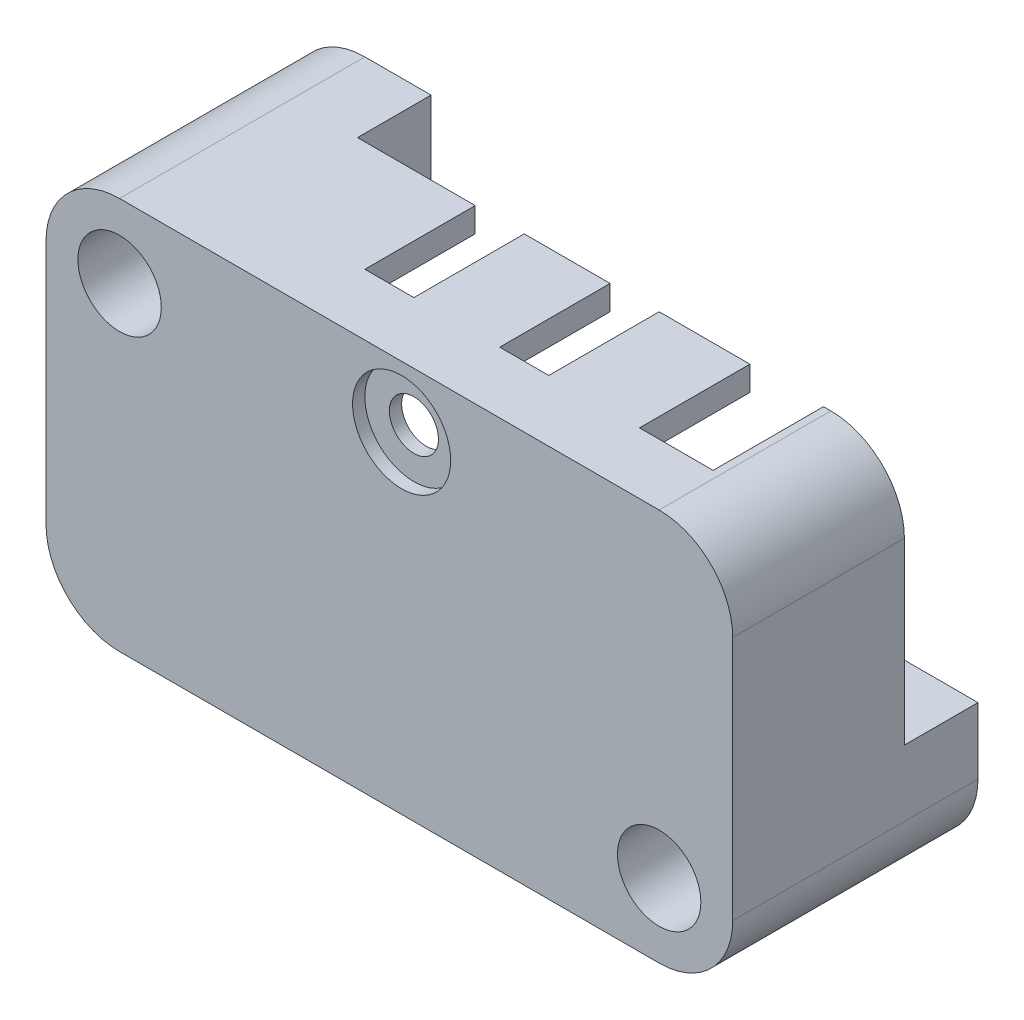
from build123d import *

# Parameters (mm, degrees)
SZKIC1_W                        = 28
SZKIC1_H                        = 16
DODANIE_WYCI_GNI_CIE1_DEPTH     = 10
WYTNIJ_WYCI_GNI_CIE1_REACH      = 12
SZKIC2_R                        = 1.7
ZAOKR_GLENIE1_R                 = 3
WYTNIJ_WYCI_GNI_CIE2_DEPTH      = 4
WYTNIJ_WYCI_GNI_CIE2_DEPTH_BACK = 4
WYTNIJ_WYCI_GNI_CIE3_DEPTH      = 3
WYTNIJ_WYCI_GNI_CIE4_REACH      = 18
SZKIC5_W                        = 2
SZKIC5_H                        = 4.5
SZKIC5_W_2                      = 3
SZKIC6_R                        = 2
WYTNIJ_WYCI_GNI_CIE5_DEPTH      = 0.5
WYTNIJ_WYCI_GNI_CIE6_REACH      = 11.5
SZKIC7_R                        = 1
WYTNIJ_WYCI_GNI_CIE7_REACH      = 30
SZKIC8_W                        = 5
SZKIC8_H                        = 1
WYTNIJ_WYCI_GNI_CIE8_REACH      = 18
SZKIC9_W                        = 1
SZKIC9_H                        = 5


with BuildPart() as part:
    # Szkic1 → Dodanie-wyciągnięcie1 (new body)
    with BuildSketch(Plane.XY):
        Rectangle(SZKIC1_W, SZKIC1_H)
    extrude(amount=DODANIE_WYCI_GNI_CIE1_DEPTH)

    # Szkic2 → Wytnij-wyciągnięcie1 (cut, up to next)
    with BuildSketch(Plane.XY.offset(10), mode=Mode.PRIVATE) as wytnij_wyci_gni_cie1_sk1:
        with Locations((-11, 5)):
            Circle(SZKIC2_R)
    wytnij_wyci_gni_cie1_tool1 = extrude(wytnij_wyci_gni_cie1_sk1.sketch, amount=-WYTNIJ_WYCI_GNI_CIE1_REACH, mode=Mode.PRIVATE) & part.part
    add(wytnij_wyci_gni_cie1_tool1.solids().sort_by_distance((-11, 5, 10))[0], mode=Mode.SUBTRACT)
    # Szkic2 → Wytnij-wyciągnięcie1 (cut, up to next)
    with BuildSketch(Plane.XY.offset(10), mode=Mode.PRIVATE) as wytnij_wyci_gni_cie1_sk2:
        with Locations((11, -5)):
            Circle(SZKIC2_R)
    wytnij_wyci_gni_cie1_tool2 = extrude(wytnij_wyci_gni_cie1_sk2.sketch, amount=-WYTNIJ_WYCI_GNI_CIE1_REACH, mode=Mode.PRIVATE) & part.part
    add(wytnij_wyci_gni_cie1_tool2.solids().sort_by_distance((11, -5, 10))[0], mode=Mode.SUBTRACT)

    # Zaokrąglenie1
    zaokr_glenie1_edges = [part.edges().sort_by_distance(p)[0] for p in [
        (14, -8, 5),
        (-14, -8, 5),
        (-14, 8, 5),
        (14, 8, 5),
    ]]
    fillet(zaokr_glenie1_edges, radius=ZAOKR_GLENIE1_R)

    # Szkic3 → Wytnij-wyciągnięcie2 (cut, two sides)
    with BuildSketch(Plane.XY.offset(5)) as wytnij_wyci_gni_cie2_sk:
        with BuildLine():
            Line((11, 7), (-7.3, 7))
            ThreePointArc((-7.3, 7), (-8.007106781, 6.707106781), (-8.3, 6))
            Line((-8.3, 6), (-8.3, 5))
            ThreePointArc((-8.3, 5), (-9.090811691, 3.090811691), (-11, 2.3))
            Line((-11, 2.3), (-12, 2.3))
            ThreePointArc((-12, 2.3), (-12.707106781, 2.007106781), (-13, 1.3))
            Line((-13, 1.3), (-13, -5))
            ThreePointArc((-13, -5), (-12.414213562, -6.414213562), (-11, -7))
            Line((-11, -7), (7.3, -7))
            ThreePointArc((7.3, -7), (8.007106781, -6.707106781), (8.3, -6))
            Line((8.3, -6), (8.3, -5))
            ThreePointArc((8.3, -5), (9.090811691, -3.090811691), (11, -2.3))
            Line((11, -2.3), (12, -2.3))
            ThreePointArc((12, -2.3), (12.707106781, -2.007106781), (13, -1.3))
            Line((13, -1.3), (13, 5))
            ThreePointArc((13, 5), (12.414213562, 6.414213562), (11, 7))
        make_face()
    extrude(amount=WYTNIJ_WYCI_GNI_CIE2_DEPTH, mode=Mode.SUBTRACT)
    extrude(wytnij_wyci_gni_cie2_sk.sketch, amount=-WYTNIJ_WYCI_GNI_CIE2_DEPTH_BACK, mode=Mode.SUBTRACT)

    # Szkic4 → Wytnij-wyciągnięcie3 (cut)
    with BuildSketch(Plane(origin=(0, 0, 0), x_dir=(-1, 0, 0), z_dir=(0, 0, -1))):
        with BuildLine():
            Line((-11, 8), (8.3, 8))
            Line((8.3, 8), (8.3, 5))
            ThreePointArc((8.3, 5), (9.090811691, 3.090811691), (11, 2.3))
            Line((11, 2.3), (14, 2.3))
            Line((14, 2.3), (14, -5))
            ThreePointArc((14, -5), (13.121320344, -7.121320344), (11, -8))
            Line((11, -8), (-8.3, -8))
            Line((-8.3, -8), (-8.3, -5))
            ThreePointArc((-8.3, -5), (-9.090811691, -3.090811691), (-11, -2.3))
            Line((-11, -2.3), (-14, -2.3))
            Line((-14, -2.3), (-14, 5))
            ThreePointArc((-14, 5), (-13.121320344, 7.121320344), (-11, 8))
        make_face()
    extrude(amount=-WYTNIJ_WYCI_GNI_CIE3_DEPTH, mode=Mode.SUBTRACT)

    # Szkic5 → Wytnij-wyciągnięcie4 (cut, up to next)
    with BuildSketch(Plane(origin=(0, 8, 0), x_dir=(1, 0, 0), z_dir=(0, 1, 0)), mode=Mode.PRIVATE) as wytnij_wyci_gni_cie4_sk1:
        with Locations((3, -5.25)):
            Rectangle(SZKIC5_W, SZKIC5_H)
    wytnij_wyci_gni_cie4_tool1 = extrude(wytnij_wyci_gni_cie4_sk1.sketch, amount=-WYTNIJ_WYCI_GNI_CIE4_REACH, mode=Mode.PRIVATE) & part.part
    add(wytnij_wyci_gni_cie4_tool1.solids().sort_by_distance((3, 8, 5.25))[0], mode=Mode.SUBTRACT)
    # Szkic5 → Wytnij-wyciągnięcie4 (cut, up to next)
    with BuildSketch(Plane(origin=(0, 8, 0), x_dir=(1, 0, 0), z_dir=(0, 1, 0)), mode=Mode.PRIVATE) as wytnij_wyci_gni_cie4_sk2:
        with Locations((9.2, -5.25)):
            Rectangle(SZKIC5_W_2, SZKIC5_H)
    wytnij_wyci_gni_cie4_tool2 = extrude(wytnij_wyci_gni_cie4_sk2.sketch, amount=-WYTNIJ_WYCI_GNI_CIE4_REACH, mode=Mode.PRIVATE) & part.part
    add(wytnij_wyci_gni_cie4_tool2.solids().sort_by_distance((9.2, 8, 5.25))[0], mode=Mode.SUBTRACT)
    # Szkic5 → Wytnij-wyciągnięcie4 (cut, up to next)
    with BuildSketch(Plane(origin=(0, 8, 0), x_dir=(1, 0, 0), z_dir=(0, 1, 0)), mode=Mode.PRIVATE) as wytnij_wyci_gni_cie4_sk3:
        with Locations((-2.5, -5.25)):
            Rectangle(SZKIC5_W, SZKIC5_H)
    wytnij_wyci_gni_cie4_tool3 = extrude(wytnij_wyci_gni_cie4_sk3.sketch, amount=-WYTNIJ_WYCI_GNI_CIE4_REACH, mode=Mode.PRIVATE) & part.part
    add(wytnij_wyci_gni_cie4_tool3.solids().sort_by_distance((-2.5, 8, 5.25))[0], mode=Mode.SUBTRACT)

    # Szkic6 → Wytnij-wyciągnięcie5 (cut)
    with BuildSketch(Plane.XY.offset(10)):
        with Locations((0.5, 5.5)):
            Circle(SZKIC6_R)
    extrude(amount=-WYTNIJ_WYCI_GNI_CIE5_DEPTH, mode=Mode.SUBTRACT)

    # Szkic7 → Wytnij-wyciągnięcie6 (cut, up to next)
    with BuildSketch(Plane.XY.offset(9.5), mode=Mode.PRIVATE) as wytnij_wyci_gni_cie6_sk1:
        with Locations((0.5, 5.5)):
            Circle(SZKIC7_R)
    wytnij_wyci_gni_cie6_tool1 = extrude(wytnij_wyci_gni_cie6_sk1.sketch, amount=-WYTNIJ_WYCI_GNI_CIE6_REACH, mode=Mode.PRIVATE) & part.part
    add(wytnij_wyci_gni_cie6_tool1.solids().sort_by_distance((0.5, 5.5, 9.5))[0], mode=Mode.SUBTRACT)

    # Szkic8 → Wytnij-wyciągnięcie7 (cut, up to next)
    with BuildSketch(Plane.ZY.offset(14), mode=Mode.PRIVATE) as wytnij_wyci_gni_cie7_sk1:
        with Locations((5.5, 1.6)):
            Rectangle(SZKIC8_W, SZKIC8_H)
    wytnij_wyci_gni_cie7_tool1 = extrude(wytnij_wyci_gni_cie7_sk1.sketch, amount=-WYTNIJ_WYCI_GNI_CIE7_REACH, mode=Mode.PRIVATE) & part.part
    add(wytnij_wyci_gni_cie7_tool1.solids().sort_by_distance((-14, 1.6, 5.5))[0], mode=Mode.SUBTRACT)
    # Szkic8 → Wytnij-wyciągnięcie7 (cut, up to next)
    with BuildSketch(Plane.ZY.offset(14), mode=Mode.PRIVATE) as wytnij_wyci_gni_cie7_sk2:
        with Locations((5.5, -3.8)):
            Rectangle(SZKIC8_W, SZKIC8_H)
    wytnij_wyci_gni_cie7_tool2 = extrude(wytnij_wyci_gni_cie7_sk2.sketch, amount=-WYTNIJ_WYCI_GNI_CIE7_REACH, mode=Mode.PRIVATE) & part.part
    add(wytnij_wyci_gni_cie7_tool2.solids().sort_by_distance((-14, -3.8, 5.5))[0], mode=Mode.SUBTRACT)

    # Szkic9 → Wytnij-wyciągnięcie8 (cut, up to next)
    with BuildSketch(Plane.XZ.offset(8), mode=Mode.PRIVATE) as wytnij_wyci_gni_cie8_sk1:
        with Locations((-2, 5.5)):
            Rectangle(SZKIC9_W, SZKIC9_H)
    wytnij_wyci_gni_cie8_tool1 = extrude(wytnij_wyci_gni_cie8_sk1.sketch, amount=-WYTNIJ_WYCI_GNI_CIE8_REACH, mode=Mode.PRIVATE) & part.part
    add(wytnij_wyci_gni_cie8_tool1.solids().sort_by_distance((-2, -8, 5.5))[0], mode=Mode.SUBTRACT)


solid = part.part
